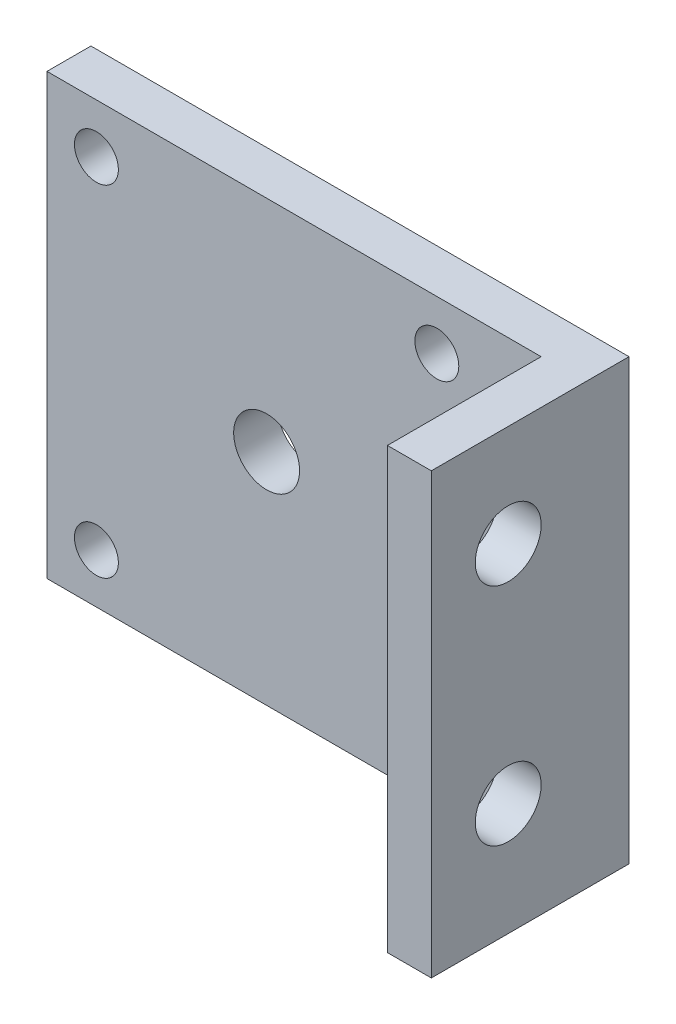
from build123d import *

# Parameters (mm, degrees)
ESQUISSE1_W             = 49
ESQUISSE1_H             = 40
BOSS_EXTRU_1_DEPTH      = 4
ESQUISSE2_W             = 4
ESQUISSE2_H             = 40
BOSS_EXTRU_2_DEPTH      = 14
ESQUISSE3_R             = 3
ENL_V_MAT_EXTRU_1_DEPTH = 4
ESQUISSE4_R             = 3
ESQUISSE4_R_2           = 2
ENL_V_MAT_EXTRU_2_DEPTH = 5


with BuildPart() as part:
    # Esquisse1 → Boss.-Extru.1 (new body)
    with BuildSketch(Plane.XY):
        with Locations((-2.585864486, -2.70959596)):
            Rectangle(ESQUISSE1_W, ESQUISSE1_H)
    extrude(amount=BOSS_EXTRU_1_DEPTH)

    # Esquisse2 → Boss.-Extru.2 (add)
    with BuildSketch(Plane.XY.offset(4)):
        with Locations((19.914135514, -2.70959596)):
            Rectangle(ESQUISSE2_W, ESQUISSE2_H)
    extrude(amount=BOSS_EXTRU_2_DEPTH)

    # Esquisse3 → Enlèv. mat.-Extru.1 (cut)
    with BuildSketch(Plane(origin=(21.914135514, 0, 0), x_dir=(0, 0, -1), z_dir=(1, 0, 0))):
        with Locations(Location((-11, 8.04040404, 0), (0, 0, 90))):  # turned: the seam where the file's is
            Circle(ESQUISSE3_R)
        with Locations(Location((-11, -12.45959596, 0), (0, 0, 90))):  # turned: the seam where the file's is
            Circle(ESQUISSE3_R)
    extrude(amount=-ENL_V_MAT_EXTRU_1_DEPTH, mode=Mode.SUBTRACT)

    # Esquisse4 → Enlèv. mat.-Extru.2 (cut, through all)
    with BuildSketch(Plane.XY.offset(4)):
        with Locations((-7.085864486, -2.70959596)):
            Circle(ESQUISSE4_R)
        with Locations((-22.585864486, 12.79040404)):
            Circle(ESQUISSE4_R_2)
        with Locations((8.414135514, 12.79040404)):
            Circle(ESQUISSE4_R_2)
        with Locations((8.414135514, -18.20959596)):
            Circle(ESQUISSE4_R_2)
        with Locations((-22.585864486, -18.20959596)):
            Circle(ESQUISSE4_R_2)
    extrude(amount=-ENL_V_MAT_EXTRU_2_DEPTH, mode=Mode.SUBTRACT)


solid = part.part
